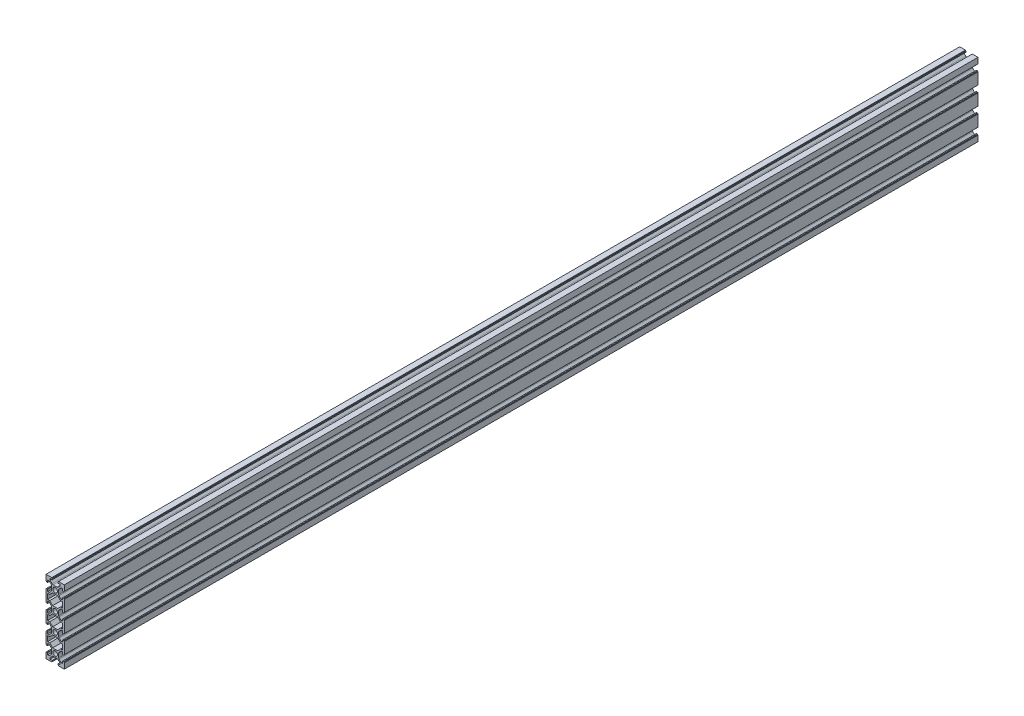
from build123d import *

# Parameters (mm, degrees)
SKETCH_3_R      = 2.5
EXTRUDE_1_DEPTH = 1000


with BuildPart() as part:
    # Эскиз3 → Бобышка-Вытянуть1 (new body)
    with BuildSketch(Plane.XY):
        with BuildLine():
            Line((-10, -5.5), (-10, -14.5))
            Line((-10, -14.5), (-10, -16.25))
            ThreePointArc((-10, -16.25), (-9.956066017, -16.356066017), (-9.85, -16.4))
            Line((-9.85, -16.4), (-9.65, -16.4))
            ThreePointArc((-9.65, -16.4), (-9.543933983, -16.443933983), (-9.5, -16.55))
            Line((-9.5, -16.55), (-9.5, -16.75))
            ThreePointArc((-9.5, -16.75), (-9.456066017, -16.856066017), (-9.35, -16.9))
            Line((-9.35, -16.9), (-8.35, -16.9))
            ThreePointArc((-8.35, -16.9), (-8.243933983, -16.856066017), (-8.2, -16.75))
            Line((-8.2, -16.75), (-8.2, -14.5))
            Line((-8.2, -14.5), (-6.6, -14.5))
            Line((-6.6, -14.5), (-4.339339828, -16.760660172))
            ThreePointArc((-4.339339828, -16.760660172), (-4.014180701, -17.247295195), (-3.9, -17.821320344))
            Line((-3.9, -17.821320344), (-3.9, -22.178679656))
            ThreePointArc((-3.9, -22.178679656), (-4.014180701, -22.752704805), (-4.339339828, -23.239339828))
            Line((-4.339339828, -23.239339828), (-6.6, -25.5))
            Line((-6.6, -25.5), (-8.2, -25.5))
            Line((-8.2, -25.5), (-8.2, -23.25))
            ThreePointArc((-8.2, -23.25), (-8.243933983, -23.143933983), (-8.35, -23.1))
            Line((-8.35, -23.1), (-9.35, -23.1))
            ThreePointArc((-9.35, -23.1), (-9.456066017, -23.143933983), (-9.5, -23.25))
            Line((-9.5, -23.25), (-9.5, -23.45))
            ThreePointArc((-9.5, -23.45), (-9.543933983, -23.556066017), (-9.65, -23.6))
            Line((-9.65, -23.6), (-9.85, -23.6))
            ThreePointArc((-9.85, -23.6), (-9.956066017, -23.643933983), (-10, -23.75))
            Line((-10, -23.75), (-10, -25.5))
            Line((-10, -25.5), (-10, -34.5))
            Line((-10, -34.5), (-10, -36.25))
            ThreePointArc((-10, -36.25), (-9.956066017, -36.356066017), (-9.85, -36.4))
            Line((-9.85, -36.4), (-9.65, -36.4))
            ThreePointArc((-9.65, -36.4), (-9.543933983, -36.443933983), (-9.5, -36.55))
            Line((-9.5, -36.55), (-9.5, -36.75))
            ThreePointArc((-9.5, -36.75), (-9.456066017, -36.856066017), (-9.35, -36.9))
            Line((-9.35, -36.9), (-8.35, -36.9))
            ThreePointArc((-8.35, -36.9), (-8.243933983, -36.856066017), (-8.2, -36.75))
            Line((-8.2, -36.75), (-8.2, -34.5))
            Line((-8.2, -34.5), (-6.6, -34.5))
            Line((-6.6, -34.5), (-4.339339828, -36.760660172))
            ThreePointArc((-4.339339828, -36.760660172), (-4.014180701, -37.247295195), (-3.9, -37.821320344))
            Line((-3.9, -37.821320344), (-3.9, -42.178679656))
            ThreePointArc((-3.9, -42.178679656), (-4.014180701, -42.752704805), (-4.339339828, -43.239339828))
            Line((-4.339339828, -43.239339828), (-6.6, -45.5))
            Line((-6.6, -45.5), (-8.2, -45.5))
            Line((-8.2, -45.5), (-8.2, -43.25))
            ThreePointArc((-8.2, -43.25), (-8.243933983, -43.143933983), (-8.35, -43.1))
            Line((-8.35, -43.1), (-9.35, -43.1))
            ThreePointArc((-9.35, -43.1), (-9.456066017, -43.143933983), (-9.5, -43.25))
            Line((-9.5, -43.25), (-9.5, -43.45))
            ThreePointArc((-9.5, -43.45), (-9.543933983, -43.556066017), (-9.65, -43.6))
            Line((-9.65, -43.6), (-9.85, -43.6))
            ThreePointArc((-9.85, -43.6), (-9.956066017, -43.643933983), (-10, -43.75))
            Line((-10, -43.75), (-10, -45.5))
            Line((-10, -45.5), (-10, -54.5))
            Line((-10, -54.5), (-10, -56.25))
            ThreePointArc((-10, -56.25), (-9.956066017, -56.356066017), (-9.85, -56.4))
            Line((-9.85, -56.4), (-9.65, -56.4))
            ThreePointArc((-9.65, -56.4), (-9.543933983, -56.443933983), (-9.5, -56.55))
            Line((-9.5, -56.55), (-9.5, -56.75))
            ThreePointArc((-9.5, -56.75), (-9.456066017, -56.856066017), (-9.35, -56.9))
            Line((-9.35, -56.9), (-8.35, -56.9))
            ThreePointArc((-8.35, -56.9), (-8.243933983, -56.856066017), (-8.2, -56.75))
            Line((-8.2, -56.75), (-8.2, -54.5))
            Line((-8.2, -54.5), (-6.6, -54.5))
            Line((-6.6, -54.5), (-4.339339828, -56.760660172))
            ThreePointArc((-4.339339828, -56.760660172), (-4.014180701, -57.247295195), (-3.9, -57.821320344))
            Line((-3.9, -57.821320344), (-3.9, -62.178679656))
            ThreePointArc((-3.9, -62.178679656), (-4.014180701, -62.752704805), (-4.339339828, -63.239339828))
            Line((-4.339339828, -63.239339828), (-6.6, -65.5))
            Line((-6.6, -65.5), (-8.2, -65.5))
            Line((-8.2, -65.5), (-8.2, -63.25))
            ThreePointArc((-8.2, -63.25), (-8.243933983, -63.143933983), (-8.35, -63.1))
            Line((-8.35, -63.1), (-9.35, -63.1))
            ThreePointArc((-9.35, -63.1), (-9.456066017, -63.143933983), (-9.5, -63.25))
            Line((-9.5, -63.25), (-9.5, -63.45))
            ThreePointArc((-9.5, -63.45), (-9.543933983, -63.556066017), (-9.65, -63.6))
            Line((-9.65, -63.6), (-9.85, -63.6))
            ThreePointArc((-9.85, -63.6), (-9.956066017, -63.643933983), (-10, -63.75))
            Line((-10, -63.75), (-10, -65.5))
            Line((-10, -65.5), (-10, -70))
            Line((-10, -70), (-5.5, -70))
            Line((-5.5, -70), (-3.75, -70))
            ThreePointArc((-3.75, -70), (-3.643933983, -69.956066017), (-3.6, -69.85))
            Line((-3.6, -69.85), (-3.6, -69.65))
            ThreePointArc((-3.6, -69.65), (-3.556066017, -69.543933983), (-3.45, -69.5))
            Line((-3.45, -69.5), (-3.25, -69.5))
            ThreePointArc((-3.25, -69.5), (-3.143933983, -69.456066017), (-3.1, -69.35))
            Line((-3.1, -69.35), (-3.1, -68.35))
            ThreePointArc((-3.1, -68.35), (-3.143933983, -68.243933983), (-3.25, -68.2))
            Line((-3.25, -68.2), (-5.5, -68.2))
            Line((-5.5, -68.2), (-5.5, -66.6))
            Line((-5.5, -66.6), (-3.239339828, -64.339339828))
            ThreePointArc((-3.239339828, -64.339339828), (-2.752704805, -64.014180701), (-2.178679656, -63.9))
            Line((-2.178679656, -63.9), (2.178679656, -63.9))
            ThreePointArc((2.178679656, -63.9), (2.752704805, -64.014180701), (3.239339828, -64.339339828))
            Line((3.239339828, -64.339339828), (5.5, -66.6))
            Line((5.5, -66.6), (5.5, -68.2))
            Line((5.5, -68.2), (3.25, -68.2))
            ThreePointArc((3.25, -68.2), (3.143933983, -68.243933983), (3.1, -68.35))
            Line((3.1, -68.35), (3.1, -69.35))
            ThreePointArc((3.1, -69.35), (3.143933983, -69.456066017), (3.25, -69.5))
            Line((3.25, -69.5), (3.45, -69.5))
            ThreePointArc((3.45, -69.5), (3.556066017, -69.543933983), (3.6, -69.65))
            Line((3.6, -69.65), (3.6, -69.85))
            ThreePointArc((3.6, -69.85), (3.643933983, -69.956066017), (3.75, -70))
            Line((3.75, -70), (5.5, -70))
            Line((5.5, -70), (10, -70))
            Line((10, -70), (10, -65.5))
            Line((10, -65.5), (10, -63.75))
            ThreePointArc((10, -63.75), (9.956066017, -63.643933983), (9.85, -63.6))
            Line((9.85, -63.6), (9.65, -63.6))
            ThreePointArc((9.65, -63.6), (9.543933983, -63.556066017), (9.5, -63.45))
            Line((9.5, -63.45), (9.5, -63.25))
            ThreePointArc((9.5, -63.25), (9.456066017, -63.143933983), (9.35, -63.1))
            Line((9.35, -63.1), (8.35, -63.1))
            ThreePointArc((8.35, -63.1), (8.243933983, -63.143933983), (8.2, -63.25))
            Line((8.2, -63.25), (8.2, -65.5))
            Line((8.2, -65.5), (6.6, -65.5))
            Line((6.6, -65.5), (4.339339828, -63.239339828))
            ThreePointArc((4.339339828, -63.239339828), (4.014180701, -62.752704805), (3.9, -62.178679656))
            Line((3.9, -62.178679656), (3.9, -57.821320344))
            ThreePointArc((3.9, -57.821320344), (4.014180701, -57.247295195), (4.339339828, -56.760660172))
            Line((4.339339828, -56.760660172), (6.6, -54.5))
            Line((6.6, -54.5), (8.2, -54.5))
            Line((8.2, -54.5), (8.2, -56.75))
            ThreePointArc((8.2, -56.75), (8.243933983, -56.856066017), (8.35, -56.9))
            Line((8.35, -56.9), (9.35, -56.9))
            ThreePointArc((9.35, -56.9), (9.456066017, -56.856066017), (9.5, -56.75))
            Line((9.5, -56.75), (9.5, -56.55))
            ThreePointArc((9.5, -56.55), (9.543933983, -56.443933983), (9.65, -56.4))
            Line((9.65, -56.4), (9.85, -56.4))
            ThreePointArc((9.85, -56.4), (9.956066017, -56.356066017), (10, -56.25))
            Line((10, -56.25), (10, -54.5))
            Line((10, -54.5), (10, -45.5))
            Line((10, -45.5), (10, -43.75))
            ThreePointArc((10, -43.75), (9.956066017, -43.643933983), (9.85, -43.6))
            Line((9.85, -43.6), (9.65, -43.6))
            ThreePointArc((9.65, -43.6), (9.543933983, -43.556066017), (9.5, -43.45))
            Line((9.5, -43.45), (9.5, -43.25))
            ThreePointArc((9.5, -43.25), (9.456066017, -43.143933983), (9.35, -43.1))
            Line((9.35, -43.1), (8.35, -43.1))
            ThreePointArc((8.35, -43.1), (8.243933983, -43.143933983), (8.2, -43.25))
            Line((8.2, -43.25), (8.2, -45.5))
            Line((8.2, -45.5), (6.6, -45.5))
            Line((6.6, -45.5), (4.339339828, -43.239339828))
            ThreePointArc((4.339339828, -43.239339828), (4.014180701, -42.752704805), (3.9, -42.178679656))
            Line((3.9, -42.178679656), (3.9, -37.821320344))
            ThreePointArc((3.9, -37.821320344), (4.014180701, -37.247295195), (4.339339828, -36.760660172))
            Line((4.339339828, -36.760660172), (6.6, -34.5))
            Line((6.6, -34.5), (8.2, -34.5))
            Line((8.2, -34.5), (8.2, -36.75))
            ThreePointArc((8.2, -36.75), (8.243933983, -36.856066017), (8.35, -36.9))
            Line((8.35, -36.9), (9.35, -36.9))
            ThreePointArc((9.35, -36.9), (9.456066017, -36.856066017), (9.5, -36.75))
            Line((9.5, -36.75), (9.5, -36.55))
            ThreePointArc((9.5, -36.55), (9.543933983, -36.443933983), (9.65, -36.4))
            Line((9.65, -36.4), (9.85, -36.4))
            ThreePointArc((9.85, -36.4), (9.956066017, -36.356066017), (10, -36.25))
            Line((10, -36.25), (10, -34.5))
            Line((10, -34.5), (10, -25.5))
            Line((10, -25.5), (10, -23.75))
            ThreePointArc((10, -23.75), (9.956066017, -23.643933983), (9.85, -23.6))
            Line((9.85, -23.6), (9.65, -23.6))
            ThreePointArc((9.65, -23.6), (9.543933983, -23.556066017), (9.5, -23.45))
            Line((9.5, -23.45), (9.5, -23.25))
            ThreePointArc((9.5, -23.25), (9.456066017, -23.143933983), (9.35, -23.1))
            Line((9.35, -23.1), (8.35, -23.1))
            ThreePointArc((8.35, -23.1), (8.243933983, -23.143933983), (8.2, -23.25))
            Line((8.2, -23.25), (8.2, -25.5))
            Line((8.2, -25.5), (6.6, -25.5))
            Line((6.6, -25.5), (4.339339828, -23.239339828))
            ThreePointArc((4.339339828, -23.239339828), (4.014180701, -22.752704805), (3.9, -22.178679656))
            Line((3.9, -22.178679656), (3.9, -17.821320344))
            ThreePointArc((3.9, -17.821320344), (4.014180701, -17.247295195), (4.339339828, -16.760660172))
            Line((4.339339828, -16.760660172), (6.6, -14.5))
            Line((6.6, -14.5), (8.2, -14.5))
            Line((8.2, -14.5), (8.2, -16.75))
            ThreePointArc((8.2, -16.75), (8.243933983, -16.856066017), (8.35, -16.9))
            Line((8.35, -16.9), (9.35, -16.9))
            ThreePointArc((9.35, -16.9), (9.456066017, -16.856066017), (9.5, -16.75))
            Line((9.5, -16.75), (9.5, -16.55))
            ThreePointArc((9.5, -16.55), (9.543933983, -16.443933983), (9.65, -16.4))
            Line((9.65, -16.4), (9.85, -16.4))
            ThreePointArc((9.85, -16.4), (9.956066017, -16.356066017), (10, -16.25))
            Line((10, -16.25), (10, -14.5))
            Line((10, -14.5), (10, -5.5))
            Line((10, -5.5), (10, -3.75))
            ThreePointArc((10, -3.75), (9.956066017, -3.643933983), (9.85, -3.6))
            Line((9.85, -3.6), (9.65, -3.6))
            ThreePointArc((9.65, -3.6), (9.543933983, -3.556066017), (9.5, -3.45))
            Line((9.5, -3.45), (9.5, -3.25))
            ThreePointArc((9.5, -3.25), (9.456066017, -3.143933983), (9.35, -3.1))
            Line((9.35, -3.1), (8.35, -3.1))
            ThreePointArc((8.35, -3.1), (8.243933983, -3.143933983), (8.2, -3.25))
            Line((8.2, -3.25), (8.2, -5.5))
            Line((8.2, -5.5), (6.6, -5.5))
            Line((6.6, -5.5), (4.339339828, -3.239339828))
            ThreePointArc((4.339339828, -3.239339828), (4.014180701, -2.752704805), (3.9, -2.178679656))
            Line((3.9, -2.178679656), (3.9, 2.178679656))
            ThreePointArc((3.9, 2.178679656), (4.014180701, 2.752704805), (4.339339828, 3.239339828))
            Line((4.339339828, 3.239339828), (6.6, 5.5))
            Line((6.6, 5.5), (8.2, 5.5))
            Line((8.2, 5.5), (8.2, 3.25))
            ThreePointArc((8.2, 3.25), (8.243933983, 3.143933983), (8.35, 3.1))
            Line((8.35, 3.1), (9.35, 3.1))
            ThreePointArc((9.35, 3.1), (9.456066017, 3.143933983), (9.5, 3.25))
            Line((9.5, 3.25), (9.5, 3.45))
            ThreePointArc((9.5, 3.45), (9.543933983, 3.556066017), (9.65, 3.6))
            Line((9.65, 3.6), (9.85, 3.6))
            ThreePointArc((9.85, 3.6), (9.956066017, 3.643933983), (10, 3.75))
            Line((10, 3.75), (10, 5.5))
            Line((10, 5.5), (10, 10))
            Line((10, 10), (5.5, 10))
            Line((5.5, 10), (3.75, 10))
            ThreePointArc((3.75, 10), (3.643933983, 9.956066017), (3.6, 9.85))
            Line((3.6, 9.85), (3.6, 9.65))
            ThreePointArc((3.6, 9.65), (3.556066017, 9.543933983), (3.45, 9.5))
            Line((3.45, 9.5), (3.25, 9.5))
            ThreePointArc((3.25, 9.5), (3.143933983, 9.456066017), (3.1, 9.35))
            Line((3.1, 9.35), (3.1, 8.35))
            ThreePointArc((3.1, 8.35), (3.143933983, 8.243933983), (3.25, 8.2))
            Line((3.25, 8.2), (5.5, 8.2))
            Line((5.5, 8.2), (5.5, 6.6))
            Line((5.5, 6.6), (3.239339828, 4.339339828))
            ThreePointArc((3.239339828, 4.339339828), (2.752704805, 4.014180701), (2.178679656, 3.9))
            Line((2.178679656, 3.9), (-2.178679656, 3.9))
            ThreePointArc((-2.178679656, 3.9), (-2.752704805, 4.014180701), (-3.239339828, 4.339339828))
            Line((-3.239339828, 4.339339828), (-5.5, 6.6))
            Line((-5.5, 6.6), (-5.5, 8.2))
            Line((-5.5, 8.2), (-3.25, 8.2))
            ThreePointArc((-3.25, 8.2), (-3.143933983, 8.243933983), (-3.1, 8.35))
            Line((-3.1, 8.35), (-3.1, 9.35))
            ThreePointArc((-3.1, 9.35), (-3.143933983, 9.456066017), (-3.25, 9.5))
            Line((-3.25, 9.5), (-3.45, 9.5))
            ThreePointArc((-3.45, 9.5), (-3.556066017, 9.543933983), (-3.6, 9.65))
            Line((-3.6, 9.65), (-3.6, 9.85))
            ThreePointArc((-3.6, 9.85), (-3.643933983, 9.956066017), (-3.75, 10))
            Line((-3.75, 10), (-5.5, 10))
            Line((-5.5, 10), (-10, 10))
            Line((-10, 10), (-10, 5.5))
            Line((-10, 5.5), (-10, 3.75))
            ThreePointArc((-10, 3.75), (-9.956066017, 3.643933983), (-9.85, 3.6))
            Line((-9.85, 3.6), (-9.65, 3.6))
            ThreePointArc((-9.65, 3.6), (-9.543933983, 3.556066017), (-9.5, 3.45))
            Line((-9.5, 3.45), (-9.5, 3.25))
            ThreePointArc((-9.5, 3.25), (-9.456066017, 3.143933983), (-9.35, 3.1))
            Line((-9.35, 3.1), (-8.35, 3.1))
            ThreePointArc((-8.35, 3.1), (-8.243933983, 3.143933983), (-8.2, 3.25))
            Line((-8.2, 3.25), (-8.2, 5.5))
            Line((-8.2, 5.5), (-6.6, 5.5))
            Line((-6.6, 5.5), (-4.339339828, 3.239339828))
            ThreePointArc((-4.339339828, 3.239339828), (-4.014180701, 2.752704805), (-3.9, 2.178679656))
            Line((-3.9, 2.178679656), (-3.9, -2.178679656))
            ThreePointArc((-3.9, -2.178679656), (-4.014180701, -2.752704805), (-4.339339828, -3.239339828))
            Line((-4.339339828, -3.239339828), (-6.6, -5.5))
            Line((-6.6, -5.5), (-8.2, -5.5))
            Line((-8.2, -5.5), (-8.2, -3.25))
            ThreePointArc((-8.2, -3.25), (-8.243933983, -3.143933983), (-8.35, -3.1))
            Line((-8.35, -3.1), (-9.35, -3.1))
            ThreePointArc((-9.35, -3.1), (-9.456066017, -3.143933983), (-9.5, -3.25))
            Line((-9.5, -3.25), (-9.5, -3.45))
            ThreePointArc((-9.5, -3.45), (-9.543933983, -3.556066017), (-9.65, -3.6))
            Line((-9.65, -3.6), (-9.85, -3.6))
            ThreePointArc((-9.85, -3.6), (-9.956066017, -3.643933983), (-10, -3.75))
            Line((-10, -3.75), (-10, -5.5))
        make_face()
        Circle(SKETCH_3_R, mode=Mode.SUBTRACT)
        with Locations((0, -20)):
            Circle(SKETCH_3_R, mode=Mode.SUBTRACT)
        with Locations((0, -40)):
            Circle(SKETCH_3_R, mode=Mode.SUBTRACT)
        with Locations((0, -60)):
            Circle(SKETCH_3_R, mode=Mode.SUBTRACT)
        Polygon((2.7372583, -3.9), (-2.7372583, -3.9), (-5.9372583, -7.1), (-8.2, -7.1), (-8.2, -12.9), (-5.9372583, -12.9), (-2.7372583, -16.1), (2.7372583, -16.1), (5.9372583, -12.9), (8.2, -12.9), (8.2, -7.1), (5.9372583, -7.1), align=None, mode=Mode.SUBTRACT)
        Polygon((-8.2, -27.1), (-8.2, -32.9), (-5.9372583, -32.9), (-2.7372583, -36.1), (2.7372583, -36.1), (5.9372583, -32.9), (8.2, -32.9), (8.2, -27.1), (5.9372583, -27.1), (2.7372583, -23.9), (-2.7372583, -23.9), (-5.9372583, -27.1), align=None, mode=Mode.SUBTRACT)
        Polygon((-8.2, -47.1), (-8.2, -52.9), (-5.9372583, -52.9), (-2.7372583, -56.1), (2.7372583, -56.1), (5.9372583, -52.9), (8.2, -52.9), (8.2, -47.1), (5.9372583, -47.1), (2.7372583, -43.9), (-2.7372583, -43.9), (-5.9372583, -47.1), align=None, mode=Mode.SUBTRACT)
    extrude(amount=EXTRUDE_1_DEPTH)


solid = part.part
